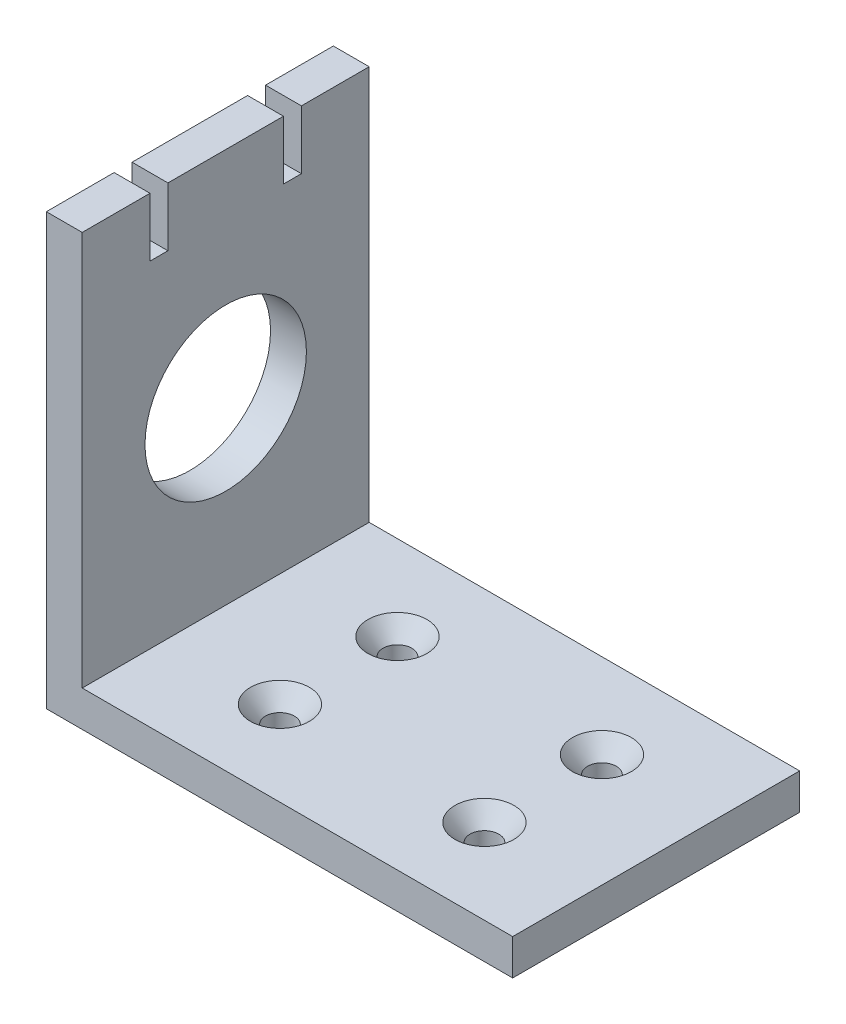
from build123d import *

# Parameters (mm, degrees)
SKETCH1_W                                          = 50.8
SKETCH1_H                                          = 76.2
BOSS_EXTRUDE1_DEPTH                                = 6.35
SKETCH2_W                                          = 50.8
SKETCH2_H                                          = 6.35
BOSS_EXTRUDE2_DEPTH                                = 76.2
SKETCH3_R                                          = 14.2875
CUT_EXTRUDE1_DEPTH                                 = 7.35
CSK_FOR_10_FLAT_HEAD_SOCKET_CAP_SCREW1_D           = 5.1054
CSK_FOR_10_FLAT_HEAD_SOCKET_CAP_SCREW1_CSINK_D     = 10.4394
CSK_FOR_10_FLAT_HEAD_SOCKET_CAP_SCREW1_CSINK_ANGLE = 82
SKETCH12_W                                         = 3.175
SKETCH12_H                                         = 10.4
CUT_EXTRUDE2_DEPTH                                 = 7.35


with BuildPart() as part:
    # Sketch1 → Boss-Extrude1 (new body)
    with BuildSketch(Plane(origin=(0, 0, 0), x_dir=(0, 0, -1), z_dir=(1, 0, 0))):
        with Locations((25.4, 38.1)):
            Rectangle(SKETCH1_W, SKETCH1_H)
    extrude(amount=BOSS_EXTRUDE1_DEPTH)

    # Sketch2 → Boss-Extrude2 (add)
    with BuildSketch(Plane(origin=(6.35, 0, 0), x_dir=(0, 0, -1), z_dir=(1, 0, 0))):
        with Locations((25.4, 3.175)):
            Rectangle(SKETCH2_W, SKETCH2_H)
    extrude(amount=BOSS_EXTRUDE2_DEPTH)

    # Sketch3 → Cut-Extrude1 (cut, through all)
    with BuildSketch(Plane(origin=(6.35, 0, 0), x_dir=(0, 0, -1), z_dir=(1, 0, 0))):
        with Locations((25.4, 38.1)):
            Circle(SKETCH3_R)
    extrude(amount=-CUT_EXTRUDE1_DEPTH, mode=Mode.SUBTRACT)

    # CSK for #10 Flat Head Socket Cap Screw1 (through all)
    with Locations(Plane(origin=(0, 6.35, 0), x_dir=(1, 0, 0), z_dir=(0, 1, 0))):
        with Locations((26.35, 35.8), (62.55, 35.8), (62.55, 15), (26.35, 15)):
            CounterSinkHole(CSK_FOR_10_FLAT_HEAD_SOCKET_CAP_SCREW1_D / 2, CSK_FOR_10_FLAT_HEAD_SOCKET_CAP_SCREW1_CSINK_D / 2, counter_sink_angle=CSK_FOR_10_FLAT_HEAD_SOCKET_CAP_SCREW1_CSINK_ANGLE)

    # Sketch12 → Cut-Extrude2 (cut, through all)
    with BuildSketch(Plane(origin=(6.35, 0, 0), x_dir=(0, 0, -1), z_dir=(1, 0, 0))):
        with Locations((37.2125, 71)):
            Rectangle(SKETCH12_W, SKETCH12_H)
        with Locations((13.5875, 71)):
            Rectangle(SKETCH12_W, SKETCH12_H)
    extrude(amount=-CUT_EXTRUDE2_DEPTH, mode=Mode.SUBTRACT)


solid = part.part
